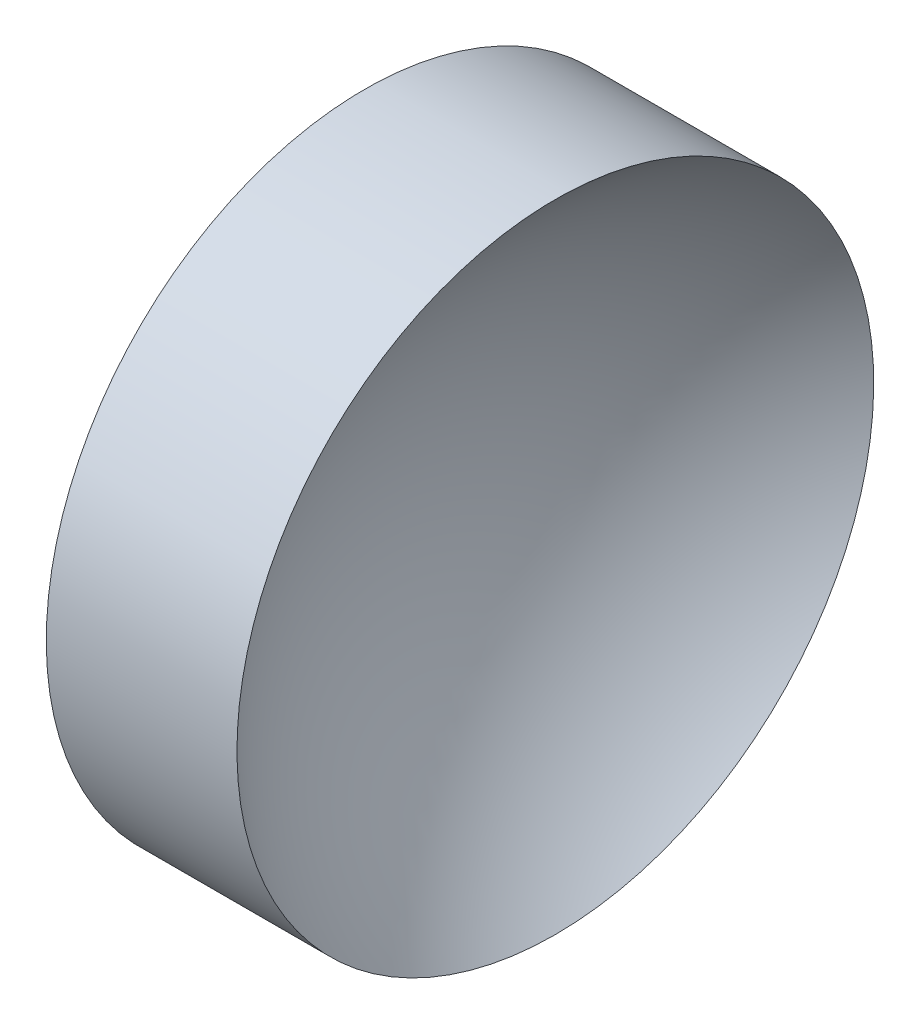
from build123d import *


with BuildPart() as part:
    # 草图1 → 旋转1 (revolve)
    with BuildSketch(Plane.XY, mode=Mode.PRIVATE) as revolve_1_sk:
        with BuildLine():
            Line((114.97544726, 65.157451827), (114.97544726, 85.157451827))
            Line((114.97544726, 85.157451827), (126.953735858, 85.157451827))
            ThreePointArc((126.953735858, 85.157451827), (119.96494167, 76.223593371), (117.47544726, 65.157451827))
            Line((117.47544726, 65.157451827), (114.97544726, 65.157451827))
        make_face()
    revolve(revolve_1_sk.sketch.rotate(Axis((110.014789249, 65.157451827, 0), (1, 0, 0)), 180), axis=Axis((110.014789249, 65.157451827, 0), (1, 0, 0)))  # turned: the seam where the file's is


solid = part.part
